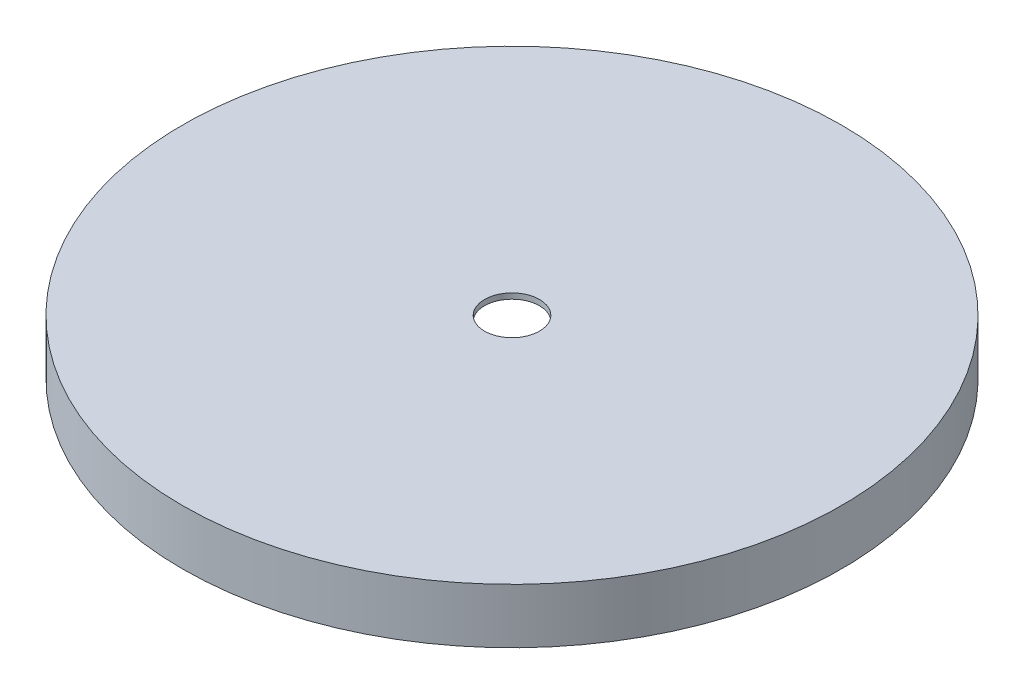
from build123d import *

# Parameters (mm, degrees)
SKETCH1_W          = 152.4
SKETCH1_H          = 25.4
SHELL2_T           = -2.54
SKETCH2_R          = 12.7
CUT_EXTRUDE1_DEPTH = 218.017695131


with BuildPart() as part:
    # Sketch1 → Revolve1 (revolve)
    with BuildSketch(Plane.XY, mode=Mode.PRIVATE) as revolve1_sk:
        with Locations((76.2, 12.7)):
            Rectangle(SKETCH1_W, SKETCH1_H)
    revolve(revolve1_sk.sketch.rotate(Axis((0, 0, 0), (0, 1, 0)), 90), axis=Axis((0, 0, 0), (0, 1, 0)))

    # Shell2
    shell2_openings = [part.faces().sort_by_distance(p)[0] for p in [
        (0, 0, 0),
    ]]
    offset(amount=SHELL2_T, openings=shell2_openings, kind=Kind.INTERSECTION)

    # Sketch2 → Cut-Extrude1 (cut, through all)
    with BuildSketch(Plane(origin=(0, 25.4, 0), x_dir=(1, 0, 0), z_dir=(0, 1, 0))):
        with Locations(Location((0, 0, 0), (0, 0, 270))):
            Circle(SKETCH2_R)
    extrude(amount=-CUT_EXTRUDE1_DEPTH, mode=Mode.SUBTRACT)


solid = part.part
